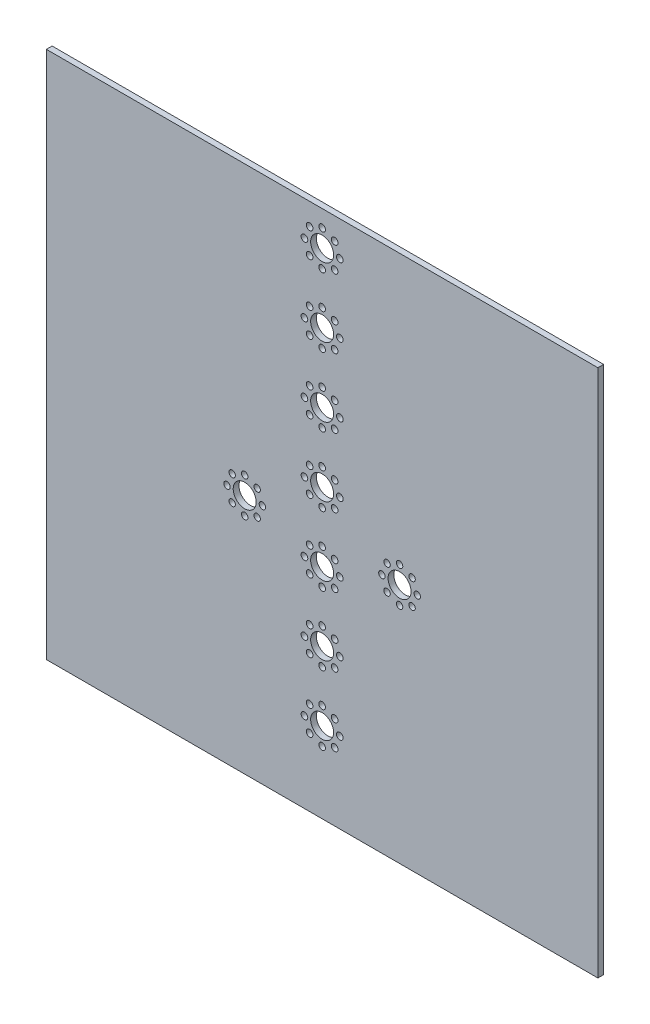
from build123d import *

# Parameters (mm, degrees)
SKETCH1_W                  = 304.8
SKETCH1_H                  = 292.1
BOSS_EXTRUDE1_DEPTH        = 3.175
SKETCH2_R                  = 1.778
CUT_EXTRUDE1_DEPTH         = 3.175
SKETCH3_R                  = 6.35
CUT_EXTRUDE2_DEPTH         = 3.175
CIRPATTERN1_COUNT          = 8
MIRROR2_COPY_1_SKETCH_R    = 1.778
MIRROR2_COPY_1_DEPTH       = 3.175
MIRROR2_COPY_2_SKETCH_R    = 1.778
MIRROR2_COPY_2_DEPTH       = 3.175
MIRROR2_COPY_3_SKETCH_R    = 1.778
MIRROR2_COPY_3_DEPTH       = 3.175
MIRROR2_COPY_4_SKETCH_R    = 1.778
MIRROR2_COPY_4_DEPTH       = 3.175
MIRROR2_COPY_5_SKETCH_R    = 1.778
MIRROR2_COPY_5_DEPTH       = 3.175
MIRROR2_COPY_6_SKETCH_R    = 1.778
MIRROR2_COPY_6_DEPTH       = 3.175
MIRROR2_COPY_7_SKETCH_R    = 1.778
MIRROR2_COPY_7_DEPTH       = 3.175
MIRROR2_COPY_8_SKETCH_R    = 1.778
MIRROR2_COPY_8_DEPTH       = 3.175
SKETCH4_R                  = 6.35
CUT_EXTRUDE3_DEPTH         = 3.175
SKETCH5_R                  = 1.8415
CUT_EXTRUDE4_DEPTH         = 3.175
CIRPATTERN2_COUNT          = 8
LPATTERN1_COUNT            = 7
LPATTERN1_PITCH            = 38.1
LPATTERN1_COPY_1_SKETCH_R  = 1.8415
LPATTERN1_COPY_1_DEPTH     = 3.175
LPATTERN1_COPY_2_SKETCH_R  = 1.8415
LPATTERN1_COPY_2_DEPTH     = 3.175
LPATTERN1_COPY_3_SKETCH_R  = 1.8415
LPATTERN1_COPY_3_DEPTH     = 3.175
LPATTERN1_COPY_4_SKETCH_R  = 1.8415
LPATTERN1_COPY_4_DEPTH     = 3.175
LPATTERN1_COPY_5_SKETCH_R  = 1.8415
LPATTERN1_COPY_5_DEPTH     = 3.175
LPATTERN1_COPY_6_SKETCH_R  = 1.8415
LPATTERN1_COPY_6_DEPTH     = 3.175
LPATTERN1_COPY_7_SKETCH_R  = 1.8415
LPATTERN1_COPY_7_DEPTH     = 3.175
LPATTERN1_COPY_8_SKETCH_R  = 1.8415
LPATTERN1_COPY_8_DEPTH     = 3.175
LPATTERN1_COPY_9_SKETCH_R  = 1.8415
LPATTERN1_COPY_9_DEPTH     = 3.175
LPATTERN1_COPY_10_SKETCH_R = 1.8415
LPATTERN1_COPY_10_DEPTH    = 3.175
LPATTERN1_COPY_11_SKETCH_R = 1.8415
LPATTERN1_COPY_11_DEPTH    = 3.175
LPATTERN1_COPY_12_SKETCH_R = 1.8415
LPATTERN1_COPY_12_DEPTH    = 3.175
LPATTERN1_COPY_13_SKETCH_R = 1.8415
LPATTERN1_COPY_13_DEPTH    = 3.175
LPATTERN1_COPY_14_SKETCH_R = 1.8415
LPATTERN1_COPY_14_DEPTH    = 3.175
LPATTERN1_COPY_15_SKETCH_R = 1.8415
LPATTERN1_COPY_15_DEPTH    = 3.175
LPATTERN1_COPY_16_SKETCH_R = 1.8415
LPATTERN1_COPY_16_DEPTH    = 3.175
LPATTERN1_COPY_17_SKETCH_R = 1.8415
LPATTERN1_COPY_17_DEPTH    = 3.175
LPATTERN1_COPY_18_SKETCH_R = 1.8415
LPATTERN1_COPY_18_DEPTH    = 3.175
LPATTERN1_COPY_19_SKETCH_R = 1.8415
LPATTERN1_COPY_19_DEPTH    = 3.175
LPATTERN1_COPY_20_SKETCH_R = 1.8415
LPATTERN1_COPY_20_DEPTH    = 3.175
LPATTERN1_COPY_21_SKETCH_R = 1.8415
LPATTERN1_COPY_21_DEPTH    = 3.175
LPATTERN1_COPY_22_SKETCH_R = 1.8415
LPATTERN1_COPY_22_DEPTH    = 3.175
LPATTERN1_COPY_23_SKETCH_R = 1.8415
LPATTERN1_COPY_23_DEPTH    = 3.175
LPATTERN1_COPY_24_SKETCH_R = 1.8415
LPATTERN1_COPY_24_DEPTH    = 3.175
LPATTERN1_COPY_25_SKETCH_R = 1.8415
LPATTERN1_COPY_25_DEPTH    = 3.175
LPATTERN1_COPY_26_SKETCH_R = 1.8415
LPATTERN1_COPY_26_DEPTH    = 3.175
LPATTERN1_COPY_27_SKETCH_R = 1.8415
LPATTERN1_COPY_27_DEPTH    = 3.175
LPATTERN1_COPY_28_SKETCH_R = 1.8415
LPATTERN1_COPY_28_DEPTH    = 3.175
LPATTERN1_COPY_29_SKETCH_R = 1.8415
LPATTERN1_COPY_29_DEPTH    = 3.175
LPATTERN1_COPY_30_SKETCH_R = 1.8415
LPATTERN1_COPY_30_DEPTH    = 3.175
LPATTERN1_COPY_31_SKETCH_R = 1.8415
LPATTERN1_COPY_31_DEPTH    = 3.175
LPATTERN1_COPY_32_SKETCH_R = 1.8415
LPATTERN1_COPY_32_DEPTH    = 3.175
LPATTERN1_COPY_33_SKETCH_R = 1.8415
LPATTERN1_COPY_33_DEPTH    = 3.175
LPATTERN1_COPY_34_SKETCH_R = 1.8415
LPATTERN1_COPY_34_DEPTH    = 3.175
LPATTERN1_COPY_35_SKETCH_R = 1.8415
LPATTERN1_COPY_35_DEPTH    = 3.175
LPATTERN1_COPY_36_SKETCH_R = 1.8415
LPATTERN1_COPY_36_DEPTH    = 3.175
LPATTERN1_COPY_37_SKETCH_R = 1.8415
LPATTERN1_COPY_37_DEPTH    = 3.175
LPATTERN1_COPY_38_SKETCH_R = 1.8415
LPATTERN1_COPY_38_DEPTH    = 3.175
LPATTERN1_COPY_39_SKETCH_R = 1.8415
LPATTERN1_COPY_39_DEPTH    = 3.175
LPATTERN1_COPY_40_SKETCH_R = 1.8415
LPATTERN1_COPY_40_DEPTH    = 3.175
LPATTERN1_COPY_41_SKETCH_R = 1.8415
LPATTERN1_COPY_41_DEPTH    = 3.175
LPATTERN1_COPY_42_SKETCH_R = 1.8415
LPATTERN1_COPY_42_DEPTH    = 3.175


with BuildPart() as part:
    # Sketch1 → Boss-Extrude1 (new body)
    with BuildSketch(Plane.XY):
        with Locations((-152.4, -146.05)):
            Rectangle(SKETCH1_W, SKETCH1_H)
    extrude(amount=BOSS_EXTRUDE1_DEPTH)

    # Sketch2 → Cut-Extrude1 (cut)
    with BuildSketch(Plane(origin=(0, 0, 0), x_dir=(-1, 0, 0), z_dir=(0, 0, -1))):
        with Locations((99.822, -158.75)):
            Circle(SKETCH2_R)
    cut_extrude1 = extrude(amount=-CUT_EXTRUDE1_DEPTH, mode=Mode.SUBTRACT)

    # Mirror1: Cut-Extrude1 across plane
    add(cut_extrude1.mirror(Plane(origin=(-152.4, 0, 0), x_dir=(0, 0, 1), z_dir=(1, 0, 0))), mode=Mode.SUBTRACT)

    # Sketch3 → Cut-Extrude2 (cut)
    with BuildSketch(Plane(origin=(0, 0, 0), x_dir=(-1, 0, 0), z_dir=(0, 0, -1))):
        with Locations((109.601, -158.75)):
            Circle(SKETCH3_R)
    cut_extrude2 = extrude(amount=-CUT_EXTRUDE2_DEPTH, mode=Mode.SUBTRACT)

    # CirPattern1: Cut-Extrude1 ×8 about axis
    cirpattern1_axis = Axis((-109.601, -158.75, 0), (0, 0, 1))
    for i in range(1, CIRPATTERN1_COUNT):
        add(cut_extrude1.rotate(cirpattern1_axis, i * 360 / CIRPATTERN1_COUNT), mode=Mode.SUBTRACT)

    # Mirror2: Cut-Extrude2 across plane
    add(cut_extrude2.mirror(Plane(origin=(-152.4, 0, 0), x_dir=(0, 0, 1), z_dir=(1, 0, 0))), mode=Mode.SUBTRACT)

    # Mirror2 copy 1 sketch → Mirror2 copy 1 (cut)
    with BuildSketch(Plane(origin=(-160.445408811, 31.002811838, 0), x_dir=(0.707106781, -0.707106781, 0), z_dir=(0, 0, -1))):
        with Locations((99.822, 158.75)):
            Circle(MIRROR2_COPY_1_SKETCH_R)
    extrude(amount=-MIRROR2_COPY_1_DEPTH, mode=Mode.SUBTRACT)

    # Mirror2 copy 2 sketch → Mirror2 copy 2 (cut)
    with BuildSketch(Plane(origin=(-36.449, -49.149, 0), x_dir=(0, -1, 0), z_dir=(0, 0, -1))):
        with Locations((99.822, 158.75)):
            Circle(MIRROR2_COPY_2_SKETCH_R)
    extrude(amount=-MIRROR2_COPY_2_DEPTH, mode=Mode.SUBTRACT)

    # Mirror2 copy 3 sketch → Mirror2 copy 3 (cut)
    with BuildSketch(Plane(origin=(-5.446188162, -193.503591189, 0), x_dir=(-0.707106781, -0.707106781, 0), z_dir=(0, 0, -1))):
        with Locations((99.822, 158.75)):
            Circle(MIRROR2_COPY_3_SKETCH_R)
    extrude(amount=-MIRROR2_COPY_3_DEPTH, mode=Mode.SUBTRACT)

    # Mirror2 copy 4 sketch → Mirror2 copy 4 (cut)
    with BuildSketch(Plane(origin=(-85.598, -317.5, 0), x_dir=(-1, 0, 0), z_dir=(0, 0, -1))):
        with Locations((99.822, 158.75)):
            Circle(MIRROR2_COPY_4_SKETCH_R)
    extrude(amount=-MIRROR2_COPY_4_DEPTH, mode=Mode.SUBTRACT)

    # Mirror2 copy 5 sketch → Mirror2 copy 5 (cut)
    with BuildSketch(Plane(origin=(-229.952591189, -348.502811838, 0), x_dir=(-0.707106781, 0.707106781, 0), z_dir=(0, 0, -1))):
        with Locations((99.822, 158.75)):
            Circle(MIRROR2_COPY_5_SKETCH_R)
    extrude(amount=-MIRROR2_COPY_5_DEPTH, mode=Mode.SUBTRACT)

    # Mirror2 copy 6 sketch → Mirror2 copy 6 (cut)
    with BuildSketch(Plane(origin=(-353.949, -268.351, 0), x_dir=(0, 1, 0), z_dir=(0, 0, -1))):
        with Locations((99.822, 158.75)):
            Circle(MIRROR2_COPY_6_SKETCH_R)
    extrude(amount=-MIRROR2_COPY_6_DEPTH, mode=Mode.SUBTRACT)

    # Mirror2 copy 7 sketch → Mirror2 copy 7 (cut)
    with BuildSketch(Plane(origin=(-384.951811838, -123.996408811, 0), x_dir=(0.707106781, 0.707106781, 0), z_dir=(0, 0, -1))):
        with Locations((99.822, 158.75)):
            Circle(MIRROR2_COPY_7_SKETCH_R)
    extrude(amount=-MIRROR2_COPY_7_DEPTH, mode=Mode.SUBTRACT)

    # Mirror2 copy 8 sketch → Mirror2 copy 8 (cut)
    with BuildSketch(Plane(origin=(-304.8, 0, 0), x_dir=(1, 0, 0), z_dir=(0, 0, -1))):
        with Locations((99.822, 158.75)):
            Circle(MIRROR2_COPY_8_SKETCH_R)
    extrude(amount=-MIRROR2_COPY_8_DEPTH, mode=Mode.SUBTRACT)

    # Sketch4 → Cut-Extrude3 (cut)
    with BuildSketch(Plane(origin=(0, 0, 0), x_dir=(-1, 0, 0), z_dir=(0, 0, -1))):
        with Locations((152.4, -19.05)):
            Circle(SKETCH4_R)
    cut_extrude3 = extrude(amount=-CUT_EXTRUDE3_DEPTH, mode=Mode.SUBTRACT)

    # Sketch5 → Cut-Extrude4 (cut)
    with BuildSketch(Plane(origin=(0, 0, 0), x_dir=(-1, 0, 0), z_dir=(0, 0, -1))):
        with Locations((152.4, -9.271)):
            Circle(SKETCH5_R)
    cut_extrude4 = extrude(amount=-CUT_EXTRUDE4_DEPTH, mode=Mode.SUBTRACT)

    # CirPattern2: Cut-Extrude4 ×8 about axis
    cirpattern2_axis = Axis((-152.4, -19.05, 0), (0, 0, 1))
    for i in range(1, CIRPATTERN2_COUNT):
        add(cut_extrude4.rotate(cirpattern2_axis, i * 360 / CIRPATTERN2_COUNT), mode=Mode.SUBTRACT)

    # LPattern1: Cut-Extrude3, Cut-Extrude4 ×7
    with Locations(*[(0, -i * LPATTERN1_PITCH, 0) for i in range(1, LPATTERN1_COUNT)]):
        add(cut_extrude3, mode=Mode.SUBTRACT)
        add(cut_extrude4, mode=Mode.SUBTRACT)

    # LPattern1 copy 1 sketch → LPattern1 copy 1 (cut)
    with BuildSketch(Plane(origin=(-58.107310729, 64.083457634, 0), x_dir=(-0.707106781, -0.707106781, 0), z_dir=(0, 0, -1))):
        with Locations((152.4, -9.271)):
            Circle(LPATTERN1_COPY_1_SKETCH_R)
    extrude(amount=-LPATTERN1_COPY_1_DEPTH, mode=Mode.SUBTRACT)

    # LPattern1 copy 2 sketch → LPattern1 copy 2 (cut)
    with BuildSketch(Plane(origin=(-58.107310729, 25.983457634, 0), x_dir=(-0.707106781, -0.707106781, 0), z_dir=(0, 0, -1))):
        with Locations((152.4, -9.271)):
            Circle(LPATTERN1_COPY_2_SKETCH_R)
    extrude(amount=-LPATTERN1_COPY_2_DEPTH, mode=Mode.SUBTRACT)

    # LPattern1 copy 3 sketch → LPattern1 copy 3 (cut)
    with BuildSketch(Plane(origin=(-58.107310729, -12.116542366, 0), x_dir=(-0.707106781, -0.707106781, 0), z_dir=(0, 0, -1))):
        with Locations((152.4, -9.271)):
            Circle(LPATTERN1_COPY_3_SKETCH_R)
    extrude(amount=-LPATTERN1_COPY_3_DEPTH, mode=Mode.SUBTRACT)

    # LPattern1 copy 4 sketch → LPattern1 copy 4 (cut)
    with BuildSketch(Plane(origin=(-58.107310729, -50.216542366, 0), x_dir=(-0.707106781, -0.707106781, 0), z_dir=(0, 0, -1))):
        with Locations((152.4, -9.271)):
            Circle(LPATTERN1_COPY_4_SKETCH_R)
    extrude(amount=-LPATTERN1_COPY_4_DEPTH, mode=Mode.SUBTRACT)

    # LPattern1 copy 5 sketch → LPattern1 copy 5 (cut)
    with BuildSketch(Plane(origin=(-58.107310729, -88.316542366, 0), x_dir=(-0.707106781, -0.707106781, 0), z_dir=(0, 0, -1))):
        with Locations((152.4, -9.271)):
            Circle(LPATTERN1_COPY_5_SKETCH_R)
    extrude(amount=-LPATTERN1_COPY_5_DEPTH, mode=Mode.SUBTRACT)

    # LPattern1 copy 6 sketch → LPattern1 copy 6 (cut)
    with BuildSketch(Plane(origin=(-58.107310729, -126.416542366, 0), x_dir=(-0.707106781, -0.707106781, 0), z_dir=(0, 0, -1))):
        with Locations((152.4, -9.271)):
            Circle(LPATTERN1_COPY_6_SKETCH_R)
    extrude(amount=-LPATTERN1_COPY_6_DEPTH, mode=Mode.SUBTRACT)

    # LPattern1 copy 7 sketch → LPattern1 copy 7 (cut)
    with BuildSketch(Plane(origin=(-171.45, 95.25, 0), x_dir=(0, -1, 0), z_dir=(0, 0, -1))):
        with Locations((152.4, -9.271)):
            Circle(LPATTERN1_COPY_7_SKETCH_R)
    extrude(amount=-LPATTERN1_COPY_7_DEPTH, mode=Mode.SUBTRACT)

    # LPattern1 copy 8 sketch → LPattern1 copy 8 (cut)
    with BuildSketch(Plane(origin=(-171.45, 57.15, 0), x_dir=(0, -1, 0), z_dir=(0, 0, -1))):
        with Locations((152.4, -9.271)):
            Circle(LPATTERN1_COPY_8_SKETCH_R)
    extrude(amount=-LPATTERN1_COPY_8_DEPTH, mode=Mode.SUBTRACT)

    # LPattern1 copy 9 sketch → LPattern1 copy 9 (cut)
    with BuildSketch(Plane(origin=(-171.45, 19.05, 0), x_dir=(0, -1, 0), z_dir=(0, 0, -1))):
        with Locations((152.4, -9.271)):
            Circle(LPATTERN1_COPY_9_SKETCH_R)
    extrude(amount=-LPATTERN1_COPY_9_DEPTH, mode=Mode.SUBTRACT)

    # LPattern1 copy 10 sketch → LPattern1 copy 10 (cut)
    with BuildSketch(Plane(origin=(-171.45, -19.05, 0), x_dir=(0, -1, 0), z_dir=(0, 0, -1))):
        with Locations((152.4, -9.271)):
            Circle(LPATTERN1_COPY_10_SKETCH_R)
    extrude(amount=-LPATTERN1_COPY_10_DEPTH, mode=Mode.SUBTRACT)

    # LPattern1 copy 11 sketch → LPattern1 copy 11 (cut)
    with BuildSketch(Plane(origin=(-171.45, -57.15, 0), x_dir=(0, -1, 0), z_dir=(0, 0, -1))):
        with Locations((152.4, -9.271)):
            Circle(LPATTERN1_COPY_11_SKETCH_R)
    extrude(amount=-LPATTERN1_COPY_11_DEPTH, mode=Mode.SUBTRACT)

    # LPattern1 copy 12 sketch → LPattern1 copy 12 (cut)
    with BuildSketch(Plane(origin=(-171.45, -95.25, 0), x_dir=(0, -1, 0), z_dir=(0, 0, -1))):
        with Locations((152.4, -9.271)):
            Circle(LPATTERN1_COPY_12_SKETCH_R)
    extrude(amount=-LPATTERN1_COPY_12_DEPTH, mode=Mode.SUBTRACT)

    # LPattern1 copy 13 sketch → LPattern1 copy 13 (cut)
    with BuildSketch(Plane(origin=(-273.633457634, 37.142689271, 0), x_dir=(0.707106781, -0.707106781, 0), z_dir=(0, 0, -1))):
        with Locations((152.4, -9.271)):
            Circle(LPATTERN1_COPY_13_SKETCH_R)
    extrude(amount=-LPATTERN1_COPY_13_DEPTH, mode=Mode.SUBTRACT)

    # LPattern1 copy 14 sketch → LPattern1 copy 14 (cut)
    with BuildSketch(Plane(origin=(-273.633457634, -0.957310729, 0), x_dir=(0.707106781, -0.707106781, 0), z_dir=(0, 0, -1))):
        with Locations((152.4, -9.271)):
            Circle(LPATTERN1_COPY_14_SKETCH_R)
    extrude(amount=-LPATTERN1_COPY_14_DEPTH, mode=Mode.SUBTRACT)

    # LPattern1 copy 15 sketch → LPattern1 copy 15 (cut)
    with BuildSketch(Plane(origin=(-273.633457634, -39.057310729, 0), x_dir=(0.707106781, -0.707106781, 0), z_dir=(0, 0, -1))):
        with Locations((152.4, -9.271)):
            Circle(LPATTERN1_COPY_15_SKETCH_R)
    extrude(amount=-LPATTERN1_COPY_15_DEPTH, mode=Mode.SUBTRACT)

    # LPattern1 copy 16 sketch → LPattern1 copy 16 (cut)
    with BuildSketch(Plane(origin=(-273.633457634, -77.157310729, 0), x_dir=(0.707106781, -0.707106781, 0), z_dir=(0, 0, -1))):
        with Locations((152.4, -9.271)):
            Circle(LPATTERN1_COPY_16_SKETCH_R)
    extrude(amount=-LPATTERN1_COPY_16_DEPTH, mode=Mode.SUBTRACT)

    # LPattern1 copy 17 sketch → LPattern1 copy 17 (cut)
    with BuildSketch(Plane(origin=(-273.633457634, -115.257310729, 0), x_dir=(0.707106781, -0.707106781, 0), z_dir=(0, 0, -1))):
        with Locations((152.4, -9.271)):
            Circle(LPATTERN1_COPY_17_SKETCH_R)
    extrude(amount=-LPATTERN1_COPY_17_DEPTH, mode=Mode.SUBTRACT)

    # LPattern1 copy 18 sketch → LPattern1 copy 18 (cut)
    with BuildSketch(Plane(origin=(-273.633457634, -153.357310729, 0), x_dir=(0.707106781, -0.707106781, 0), z_dir=(0, 0, -1))):
        with Locations((152.4, -9.271)):
            Circle(LPATTERN1_COPY_18_SKETCH_R)
    extrude(amount=-LPATTERN1_COPY_18_DEPTH, mode=Mode.SUBTRACT)

    # LPattern1 copy 19 sketch → LPattern1 copy 19 (cut)
    with BuildSketch(Plane(origin=(-304.8, -76.2, 0), x_dir=(1, 0, 0), z_dir=(0, 0, -1))):
        with Locations((152.4, -9.271)):
            Circle(LPATTERN1_COPY_19_SKETCH_R)
    extrude(amount=-LPATTERN1_COPY_19_DEPTH, mode=Mode.SUBTRACT)

    # LPattern1 copy 20 sketch → LPattern1 copy 20 (cut)
    with BuildSketch(Plane(origin=(-304.8, -114.3, 0), x_dir=(1, 0, 0), z_dir=(0, 0, -1))):
        with Locations((152.4, -9.271)):
            Circle(LPATTERN1_COPY_20_SKETCH_R)
    extrude(amount=-LPATTERN1_COPY_20_DEPTH, mode=Mode.SUBTRACT)

    # LPattern1 copy 21 sketch → LPattern1 copy 21 (cut)
    with BuildSketch(Plane(origin=(-304.8, -152.4, 0), x_dir=(1, 0, 0), z_dir=(0, 0, -1))):
        with Locations((152.4, -9.271)):
            Circle(LPATTERN1_COPY_21_SKETCH_R)
    extrude(amount=-LPATTERN1_COPY_21_DEPTH, mode=Mode.SUBTRACT)

    # LPattern1 copy 22 sketch → LPattern1 copy 22 (cut)
    with BuildSketch(Plane(origin=(-304.8, -190.5, 0), x_dir=(1, 0, 0), z_dir=(0, 0, -1))):
        with Locations((152.4, -9.271)):
            Circle(LPATTERN1_COPY_22_SKETCH_R)
    extrude(amount=-LPATTERN1_COPY_22_DEPTH, mode=Mode.SUBTRACT)

    # LPattern1 copy 23 sketch → LPattern1 copy 23 (cut)
    with BuildSketch(Plane(origin=(-304.8, -228.6, 0), x_dir=(1, 0, 0), z_dir=(0, 0, -1))):
        with Locations((152.4, -9.271)):
            Circle(LPATTERN1_COPY_23_SKETCH_R)
    extrude(amount=-LPATTERN1_COPY_23_DEPTH, mode=Mode.SUBTRACT)

    # LPattern1 copy 24 sketch → LPattern1 copy 24 (cut)
    with BuildSketch(Plane(origin=(-304.8, -266.7, 0), x_dir=(1, 0, 0), z_dir=(0, 0, -1))):
        with Locations((152.4, -9.271)):
            Circle(LPATTERN1_COPY_24_SKETCH_R)
    extrude(amount=-LPATTERN1_COPY_24_DEPTH, mode=Mode.SUBTRACT)

    # LPattern1 copy 25 sketch → LPattern1 copy 25 (cut)
    with BuildSketch(Plane(origin=(-246.692689271, -178.383457634, 0), x_dir=(0.707106781, 0.707106781, 0), z_dir=(0, 0, -1))):
        with Locations((152.4, -9.271)):
            Circle(LPATTERN1_COPY_25_SKETCH_R)
    extrude(amount=-LPATTERN1_COPY_25_DEPTH, mode=Mode.SUBTRACT)

    # LPattern1 copy 26 sketch → LPattern1 copy 26 (cut)
    with BuildSketch(Plane(origin=(-246.692689271, -216.483457634, 0), x_dir=(0.707106781, 0.707106781, 0), z_dir=(0, 0, -1))):
        with Locations((152.4, -9.271)):
            Circle(LPATTERN1_COPY_26_SKETCH_R)
    extrude(amount=-LPATTERN1_COPY_26_DEPTH, mode=Mode.SUBTRACT)

    # LPattern1 copy 27 sketch → LPattern1 copy 27 (cut)
    with BuildSketch(Plane(origin=(-246.692689271, -254.583457634, 0), x_dir=(0.707106781, 0.707106781, 0), z_dir=(0, 0, -1))):
        with Locations((152.4, -9.271)):
            Circle(LPATTERN1_COPY_27_SKETCH_R)
    extrude(amount=-LPATTERN1_COPY_27_DEPTH, mode=Mode.SUBTRACT)

    # LPattern1 copy 28 sketch → LPattern1 copy 28 (cut)
    with BuildSketch(Plane(origin=(-246.692689271, -292.683457634, 0), x_dir=(0.707106781, 0.707106781, 0), z_dir=(0, 0, -1))):
        with Locations((152.4, -9.271)):
            Circle(LPATTERN1_COPY_28_SKETCH_R)
    extrude(amount=-LPATTERN1_COPY_28_DEPTH, mode=Mode.SUBTRACT)

    # LPattern1 copy 29 sketch → LPattern1 copy 29 (cut)
    with BuildSketch(Plane(origin=(-246.692689271, -330.783457634, 0), x_dir=(0.707106781, 0.707106781, 0), z_dir=(0, 0, -1))):
        with Locations((152.4, -9.271)):
            Circle(LPATTERN1_COPY_29_SKETCH_R)
    extrude(amount=-LPATTERN1_COPY_29_DEPTH, mode=Mode.SUBTRACT)

    # LPattern1 copy 30 sketch → LPattern1 copy 30 (cut)
    with BuildSketch(Plane(origin=(-246.692689271, -368.883457634, 0), x_dir=(0.707106781, 0.707106781, 0), z_dir=(0, 0, -1))):
        with Locations((152.4, -9.271)):
            Circle(LPATTERN1_COPY_30_SKETCH_R)
    extrude(amount=-LPATTERN1_COPY_30_DEPTH, mode=Mode.SUBTRACT)

    # LPattern1 copy 31 sketch → LPattern1 copy 31 (cut)
    with BuildSketch(Plane(origin=(-133.35, -209.55, 0), x_dir=(0, 1, 0), z_dir=(0, 0, -1))):
        with Locations((152.4, -9.271)):
            Circle(LPATTERN1_COPY_31_SKETCH_R)
    extrude(amount=-LPATTERN1_COPY_31_DEPTH, mode=Mode.SUBTRACT)

    # LPattern1 copy 32 sketch → LPattern1 copy 32 (cut)
    with BuildSketch(Plane(origin=(-133.35, -247.65, 0), x_dir=(0, 1, 0), z_dir=(0, 0, -1))):
        with Locations((152.4, -9.271)):
            Circle(LPATTERN1_COPY_32_SKETCH_R)
    extrude(amount=-LPATTERN1_COPY_32_DEPTH, mode=Mode.SUBTRACT)

    # LPattern1 copy 33 sketch → LPattern1 copy 33 (cut)
    with BuildSketch(Plane(origin=(-133.35, -285.75, 0), x_dir=(0, 1, 0), z_dir=(0, 0, -1))):
        with Locations((152.4, -9.271)):
            Circle(LPATTERN1_COPY_33_SKETCH_R)
    extrude(amount=-LPATTERN1_COPY_33_DEPTH, mode=Mode.SUBTRACT)

    # LPattern1 copy 34 sketch → LPattern1 copy 34 (cut)
    with BuildSketch(Plane(origin=(-133.35, -323.85, 0), x_dir=(0, 1, 0), z_dir=(0, 0, -1))):
        with Locations((152.4, -9.271)):
            Circle(LPATTERN1_COPY_34_SKETCH_R)
    extrude(amount=-LPATTERN1_COPY_34_DEPTH, mode=Mode.SUBTRACT)

    # LPattern1 copy 35 sketch → LPattern1 copy 35 (cut)
    with BuildSketch(Plane(origin=(-133.35, -361.95, 0), x_dir=(0, 1, 0), z_dir=(0, 0, -1))):
        with Locations((152.4, -9.271)):
            Circle(LPATTERN1_COPY_35_SKETCH_R)
    extrude(amount=-LPATTERN1_COPY_35_DEPTH, mode=Mode.SUBTRACT)

    # LPattern1 copy 36 sketch → LPattern1 copy 36 (cut)
    with BuildSketch(Plane(origin=(-133.35, -400.05, 0), x_dir=(0, 1, 0), z_dir=(0, 0, -1))):
        with Locations((152.4, -9.271)):
            Circle(LPATTERN1_COPY_36_SKETCH_R)
    extrude(amount=-LPATTERN1_COPY_36_DEPTH, mode=Mode.SUBTRACT)

    # LPattern1 copy 37 sketch → LPattern1 copy 37 (cut)
    with BuildSketch(Plane(origin=(-31.166542366, -151.442689271, 0), x_dir=(-0.707106781, 0.707106781, 0), z_dir=(0, 0, -1))):
        with Locations((152.4, -9.271)):
            Circle(LPATTERN1_COPY_37_SKETCH_R)
    extrude(amount=-LPATTERN1_COPY_37_DEPTH, mode=Mode.SUBTRACT)

    # LPattern1 copy 38 sketch → LPattern1 copy 38 (cut)
    with BuildSketch(Plane(origin=(-31.166542366, -189.542689271, 0), x_dir=(-0.707106781, 0.707106781, 0), z_dir=(0, 0, -1))):
        with Locations((152.4, -9.271)):
            Circle(LPATTERN1_COPY_38_SKETCH_R)
    extrude(amount=-LPATTERN1_COPY_38_DEPTH, mode=Mode.SUBTRACT)

    # LPattern1 copy 39 sketch → LPattern1 copy 39 (cut)
    with BuildSketch(Plane(origin=(-31.166542366, -227.642689271, 0), x_dir=(-0.707106781, 0.707106781, 0), z_dir=(0, 0, -1))):
        with Locations((152.4, -9.271)):
            Circle(LPATTERN1_COPY_39_SKETCH_R)
    extrude(amount=-LPATTERN1_COPY_39_DEPTH, mode=Mode.SUBTRACT)

    # LPattern1 copy 40 sketch → LPattern1 copy 40 (cut)
    with BuildSketch(Plane(origin=(-31.166542366, -265.742689271, 0), x_dir=(-0.707106781, 0.707106781, 0), z_dir=(0, 0, -1))):
        with Locations((152.4, -9.271)):
            Circle(LPATTERN1_COPY_40_SKETCH_R)
    extrude(amount=-LPATTERN1_COPY_40_DEPTH, mode=Mode.SUBTRACT)

    # LPattern1 copy 41 sketch → LPattern1 copy 41 (cut)
    with BuildSketch(Plane(origin=(-31.166542366, -303.842689271, 0), x_dir=(-0.707106781, 0.707106781, 0), z_dir=(0, 0, -1))):
        with Locations((152.4, -9.271)):
            Circle(LPATTERN1_COPY_41_SKETCH_R)
    extrude(amount=-LPATTERN1_COPY_41_DEPTH, mode=Mode.SUBTRACT)

    # LPattern1 copy 42 sketch → LPattern1 copy 42 (cut)
    with BuildSketch(Plane(origin=(-31.166542366, -341.942689271, 0), x_dir=(-0.707106781, 0.707106781, 0), z_dir=(0, 0, -1))):
        with Locations((152.4, -9.271)):
            Circle(LPATTERN1_COPY_42_SKETCH_R)
    extrude(amount=-LPATTERN1_COPY_42_DEPTH, mode=Mode.SUBTRACT)


solid = part.part
